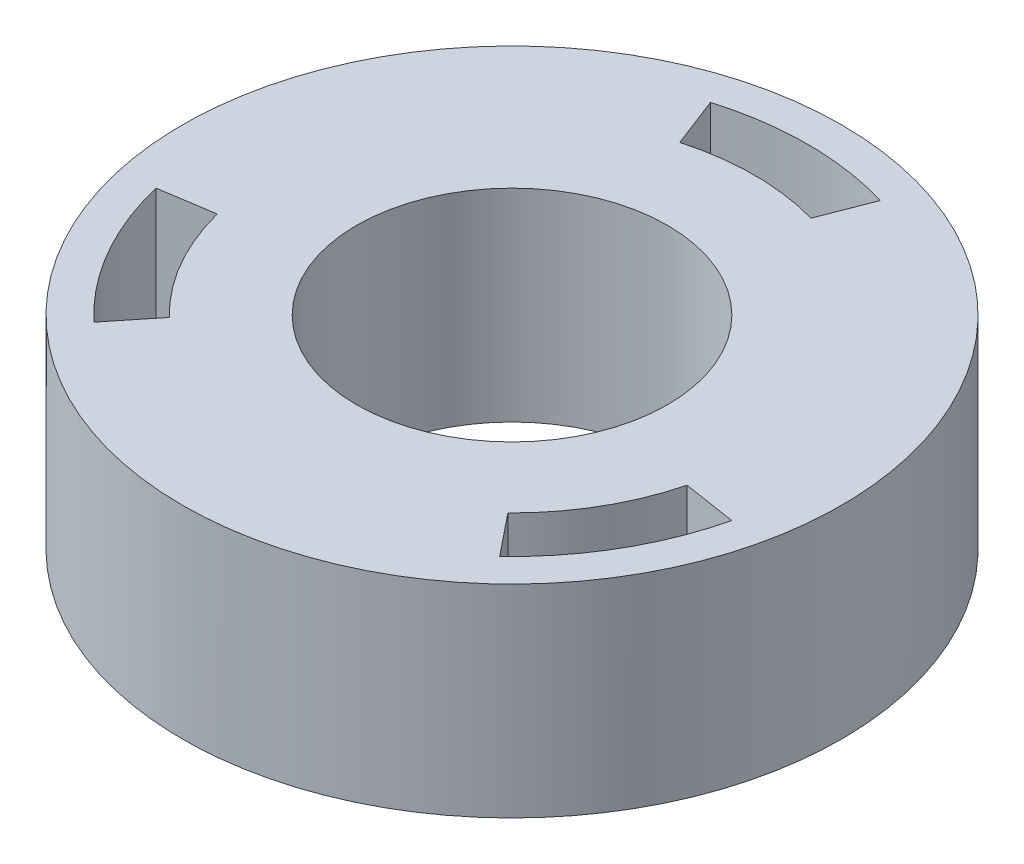
from build123d import *

# Parameters (mm, degrees)
SKETCH1_R           = 19.36
BOSS_EXTRUDE1_DEPTH = 10
CUT_EXTRUDE1_REACH  = 12
CUT_EXTRUDE2_REACH  = 12
SKETCH3_R           = 9.21
SKETCH4_R           = 19.36
SKETCH4_R_2         = 9.21
BOSS_EXTRUDE2_DEPTH = 2
SKETCH5_R           = 19.522617412
SKETCH5_R_2         = 17.522617412
BOSS_EXTRUDE3_DEPTH = 12


with BuildPart() as part:
    # Sketch1 → Boss-Extrude1 (new body)
    with BuildSketch(Plane(origin=(0, 0, 0), x_dir=(1, 0, 0), z_dir=(0, 1, 0))):
        Circle(SKETCH1_R)
    extrude(amount=BOSS_EXTRUDE1_DEPTH)

    # Sketch2 → Cut-Extrude1 (cut, up to next)
    with BuildSketch(Plane.XZ, mode=Mode.PRIVATE) as cut_extrude1_sk1:
        with BuildLine():
            Line((13.175859246, 14.184721821), (10.029502225, 10.277095169))
            ThreePointArc((10.029502225, 10.277095169), (12.436124798, 7.18), (13.914976606, 3.54725613))
            Line((13.914976606, 3.54725613), (18.872259065, 4.318267913))
            ThreePointArc((18.872259065, 4.318267913), (16.766251817, 9.68), (13.175859246, 14.184721821))
        make_face()
    cut_extrude1_tool1 = extrude(cut_extrude1_sk1.sketch, amount=-CUT_EXTRUDE1_REACH, mode=Mode.PRIVATE) & part.part
    add(cut_extrude1_tool1.solids().sort_by_distance((14.534106, 0, 8.39127))[0], mode=Mode.SUBTRACT)
    # Sketch2 → Cut-Extrude1 (cut, up to next)
    with BuildSketch(Plane.XZ, mode=Mode.PRIVATE) as cut_extrude1_sk2:
        with BuildLine():
            ThreePointArc((-13.914976606, 3.54725613), (-12.436124798, 7.18), (-10.029502225, 10.277095169))
            Line((-10.029502225, 10.277095169), (-13.175859246, 14.184721821))
            ThreePointArc((-13.175859246, 14.184721821), (-16.766251817, 9.68), (-18.872259065, 4.318267913))
            Line((-18.872259065, 4.318267913), (-13.914976606, 3.54725613))
        make_face()
    cut_extrude1_tool2 = extrude(cut_extrude1_sk2.sketch, amount=-CUT_EXTRUDE1_REACH, mode=Mode.PRIVATE) & part.part
    add(cut_extrude1_tool2.solids().sort_by_distance((-14.534106, 0, 8.39127))[0], mode=Mode.SUBTRACT)
    # Sketch2 → Cut-Extrude1 (cut, up to next)
    with BuildSketch(Plane.XZ, mode=Mode.PRIVATE) as cut_extrude1_sk3:
        with BuildLine():
            Line((5.69639982, -18.502989734), (3.885474381, -13.824351299))
            ThreePointArc((3.885474381, -13.824351299), (0, -14.36), (-3.885474381, -13.824351299))
            Line((-3.885474381, -13.824351299), (-5.69639982, -18.502989734))
            ThreePointArc((-5.69639982, -18.502989734), (0, -19.36), (5.69639982, -18.502989734))
        make_face()
    cut_extrude1_tool3 = extrude(cut_extrude1_sk3.sketch, amount=-CUT_EXTRUDE1_REACH, mode=Mode.PRIVATE) & part.part
    add(cut_extrude1_tool3.solids().sort_by_distance((0, 0, -16.782541))[0], mode=Mode.SUBTRACT)

    # Sketch3 → Cut-Extrude2 (cut, up to next)
    with BuildSketch(Plane.XZ, mode=Mode.PRIVATE) as cut_extrude2_sk1:
        Circle(SKETCH3_R)
    cut_extrude2_tool1 = extrude(cut_extrude2_sk1.sketch, amount=-CUT_EXTRUDE2_REACH, mode=Mode.PRIVATE) & part.part
    add(cut_extrude2_tool1.solids().sort_by_distance((0, 0, 0))[0], mode=Mode.SUBTRACT)

    # Sketch4 → Boss-Extrude2 (add)
    with BuildSketch(Plane.XZ):
        Circle(SKETCH4_R)
        Circle(SKETCH4_R_2, mode=Mode.SUBTRACT)
    extrude(amount=BOSS_EXTRUDE2_DEPTH)

    # Sketch5 → Boss-Extrude3 (add)
    with BuildSketch(Plane.XZ.offset(2)):
        Circle(SKETCH5_R)
        Circle(SKETCH5_R_2, mode=Mode.SUBTRACT)
    extrude(amount=-BOSS_EXTRUDE3_DEPTH)


solid = part.part
